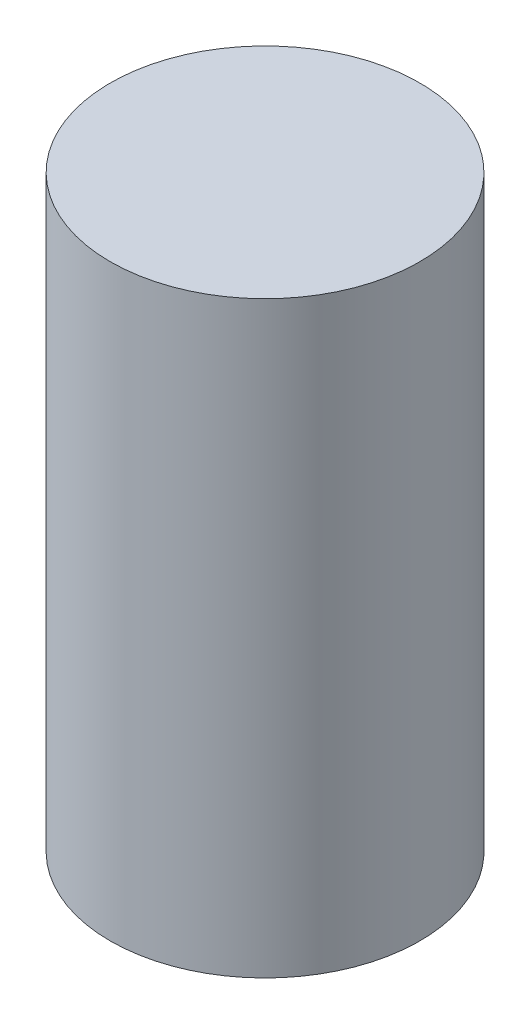
from build123d import *

# Parameters (mm, degrees)
SKETCH1_R           = 32.5
BOSS_EXTRUDE1_DEPTH = 123.5


with BuildPart() as part:
    # Sketch1 → Boss-Extrude1 (new body)
    with BuildSketch(Plane(origin=(0, 0, 0), x_dir=(1, 0, 0), z_dir=(0, 1, 0))):
        Circle(SKETCH1_R)
    extrude(amount=BOSS_EXTRUDE1_DEPTH)


solid = part.part
